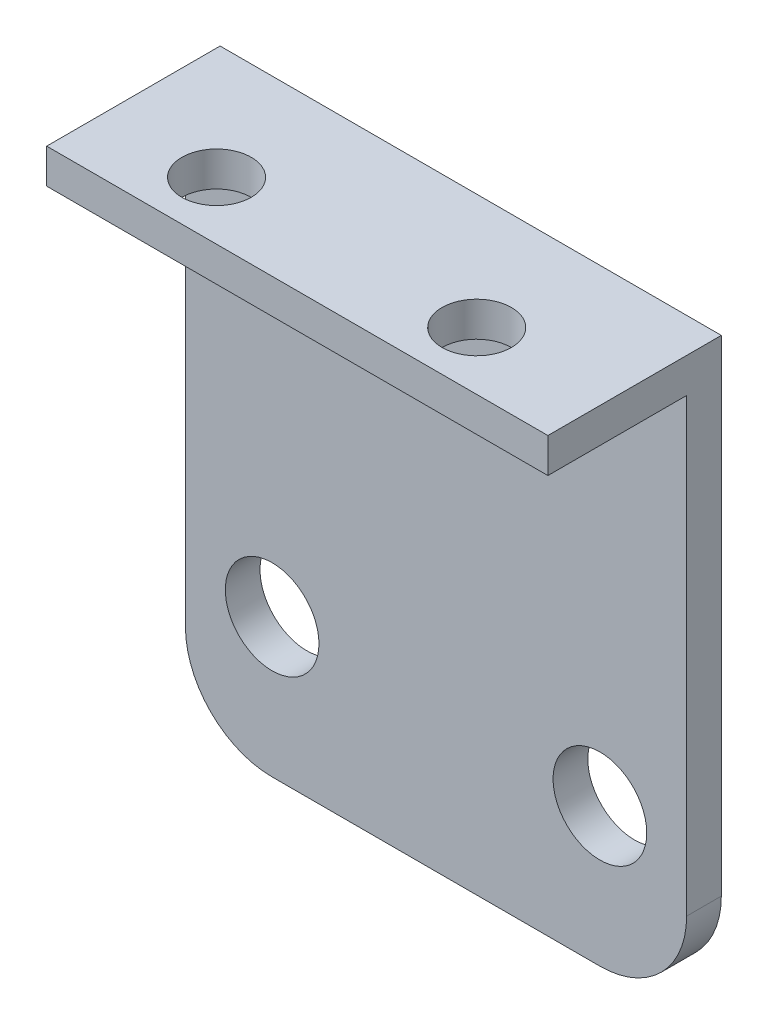
from build123d import *

# Parameters (mm, degrees)
SKETCH1_W           = 28.9
SKETCH1_H           = 33
SKETCH1_R           = 2.7
BOSS_EXTRUDE1_DEPTH = 2
FILLET1_R           = 5
SKETCH3_W           = 28.9
SKETCH3_H           = 2
BOSS_EXTRUDE3_DEPTH = 8
SKETCH5_R           = 2
CUT_EXTRUDE2_DEPTH  = 10


with BuildPart() as part:
    # Sketch1 → Boss-Extrude1 (new body)
    with BuildSketch(Plane.XY):
        with Locations((0.904740234, 58.092544957)):
            Rectangle(SKETCH1_W, SKETCH1_H)
        with Locations((-8.545259766, 49.592544957)):
            Circle(SKETCH1_R, mode=Mode.SUBTRACT)
        with Locations((10.354740234, 49.592544957)):
            Circle(SKETCH1_R, mode=Mode.SUBTRACT)
    extrude(amount=BOSS_EXTRUDE1_DEPTH)

    # Fillet1
    fillet1_edges = [part.edges().sort_by_distance(p)[0] for p in [
        (15.354740234, 41.592544957, 1),
        (-13.545259766, 41.592544957, 1),
    ]]
    fillet(fillet1_edges, radius=FILLET1_R)

    # Sketch3 → Boss-Extrude3 (add)
    with BuildSketch(Plane.XY.offset(2)):
        with Locations((0.904740234, 73.592544957)):
            Rectangle(SKETCH3_W, SKETCH3_H)
    extrude(amount=BOSS_EXTRUDE3_DEPTH)

    # Sketch5 → Cut-Extrude2 (cut)
    with BuildSketch(Plane(origin=(0, 74.592544957, 0), x_dir=(1, 0, 0), z_dir=(0, 1, 0))):
        with Locations((-7.091615714, -6.658195947)):
            Circle(SKETCH5_R)
        with Locations((7.908384286, -6.658195947)):
            Circle(SKETCH5_R)
    extrude(amount=-CUT_EXTRUDE2_DEPTH, mode=Mode.SUBTRACT)


solid = part.part
